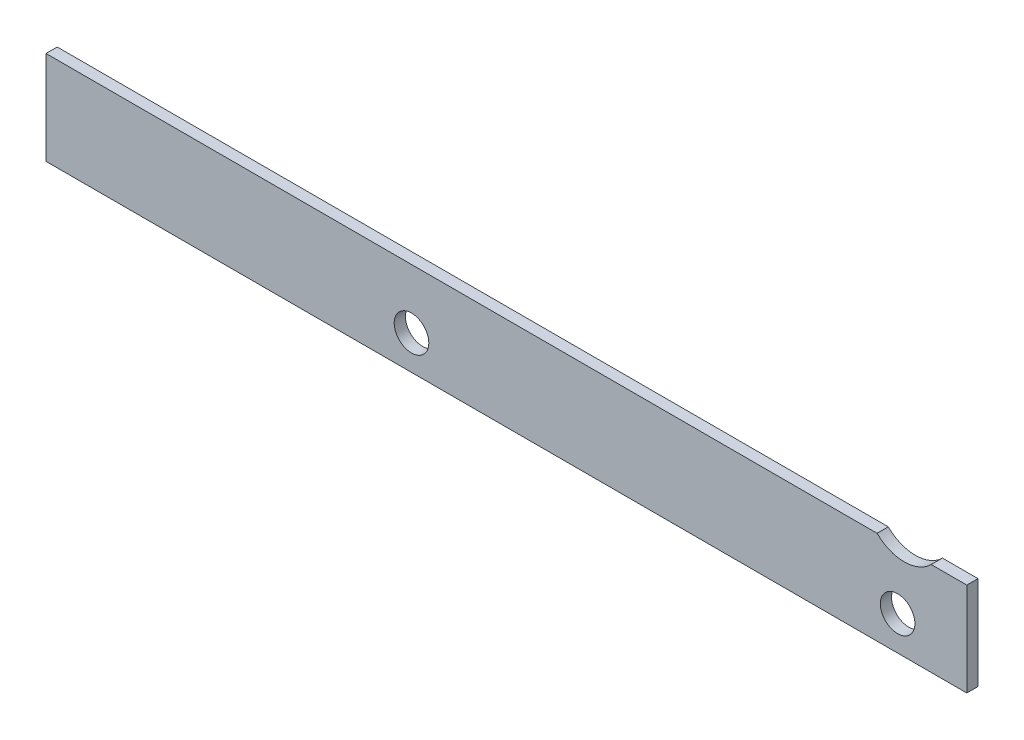
from build123d import *

# Parameters (mm, degrees)
SALIENTE_EXTRUIR1_DEPTH = 12
CROQUIS2_R              = 18.5
CORTAR_EXTRUIR1_DEPTH   = 13
CROQUIS3_R              = 18.5
CORTAR_EXTRUIR2_DEPTH   = 13


with BuildPart() as part:
    # Croquis1 → Saliente-Extruir1 (new body)
    with BuildSketch(Plane.XY):
        with BuildLine():
            Line((0, 0), (985, 0))
            Line((985, 0), (985, 100))
            Line((985, 100), (946.952353927, 100))
            ThreePointArc((946.952353927, 100), (918, 88.021483703), (889.047646073, 100))
            Line((889.047646073, 100), (0, 100))
            Line((0, 100), (0, 0))
        make_face()
    extrude(amount=SALIENTE_EXTRUIR1_DEPTH)

    # Croquis2 → Cortar-Extruir1 (cut, through all)
    with BuildSketch(Plane.XY.offset(12)):
        with Locations((911, 36.5)):
            Circle(CROQUIS2_R)
    extrude(amount=-CORTAR_EXTRUIR1_DEPTH, mode=Mode.SUBTRACT)

    # Croquis3 → Cortar-Extruir2 (cut, through all)
    with BuildSketch(Plane.XY.offset(12)):
        with Locations((391, 36.5)):
            Circle(CROQUIS3_R)
    extrude(amount=-CORTAR_EXTRUIR2_DEPTH, mode=Mode.SUBTRACT)


solid = part.part
